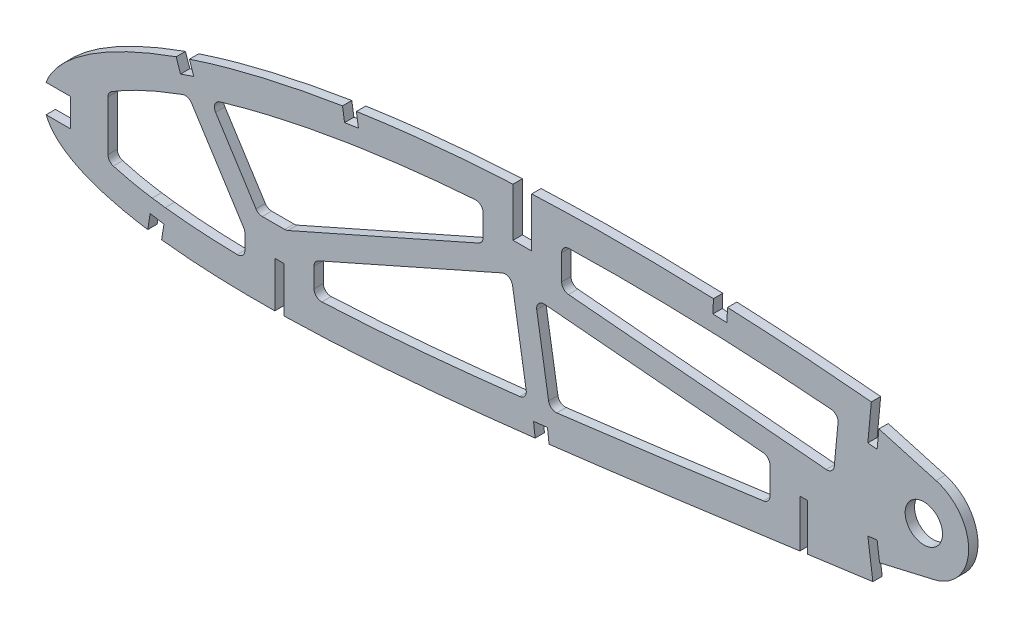
from build123d import *

# Parameters (mm, degrees)
BOSS_EXTRUDE1_DEPTH = 3.175
CUT_EXTRUDE1_DEPTH  = 7.62
SKETCH3_R           = 6.35
CUT_EXTRUDE2_DEPTH  = 7.62
CUT_EXTRUDE3_DEPTH  = 460.680430564
CUT_EXTRUDE4_DEPTH  = 320.461002544
FILLET1_R           = 2.54


with BuildPart() as part:
    # Sketch1 → Boss-Extrude1 (new body)
    with BuildSketch(Plane.XY):
        with BuildLine():
            Line((452.103130844, 0.704841059), (456.093968789, -1.676407199))
            Line((456.093968789, -1.676407199), (451.539257956, -0.704841059))
            add(Edge.make_bspline(
                [(0, 0), (0.116098484, -0.548062271), (0.348829019, -1.646705608), (0.981127511, -3.228296827), (1.817312083, -4.748664111), (2.874932324, -6.203769023), (4.146956076, -7.593213852), (5.630573928, -8.918443806), (7.324330898, -10.17874635), (9.226010202, -11.373547856), (11.332849305, -12.504116729), (13.642480166, -13.569749989), (16.152796843, -14.570114683), (18.861064307, -15.503873502), (21.763971588, -16.372448625), (24.858758771, -17.173723352), (28.141906776, -17.908817596), (31.610257831, -18.575854993), (35.260032504, -19.175513209), (39.087439203, -19.707456616), (43.088549366, -20.172017908), (47.259437594, -20.568222339), (51.595978462, -20.896922095), (56.093849686, -21.158335191), (60.748685259, -21.353290574), (65.556026339, -21.481047186), (70.511164689, -21.543596642), (75.60962225, -21.541878079), (80.846411515, -21.475431763), (86.217059019, -21.347928406), (91.716411041, -21.158560481), (97.339502767, -20.909619435), (103.081262098, -20.60361064), (108.936539298, -20.241571378), (114.900181528, -19.825106256), (120.967010704, -19.35755507), (127.131515672, -18.84008407), (133.388320155, -18.27570942), (139.73188498, -17.667256592), (146.156729407, -17.016651105), (152.657182369, -16.326953548), (159.227454029, -15.600398833), (165.861955098, -14.840863119), (172.554624992, -14.049720613), (179.299804335, -13.231488425), (186.0911476, -12.387729793), (192.922975871, -11.521694689), (199.789144556, -10.637460813), (206.683225759, -9.734927313), (213.599421065, -8.820524357), (220.53106073, -7.893498895), (227.472111233, -6.958618548), (234.416147314, -6.018789286), (241.356405409, -5.07430035), (248.28678484, -4.129065861), (255.200856388, -3.185680808), (262.091847615, -2.244231265), (268.953524037, -1.309396646), (275.778976202, -0.38106275), (282.561910312, 0.538888344), (289.295826346, 1.447710664), (295.974371147, 2.344257157), (302.590655451, 3.227960607), (309.138022785, 4.099152889), (315.511866205, 4.931391047), (321.69553077, 5.768992271), (327.709854245, 6.4556395), (333.649291775, 7.04171769), (339.520012945, 7.522220911), (345.31496828, 7.904062197), (351.027518107, 8.189969928), (356.650854245, 8.383935735), (362.17787359, 8.491713952), (367.601672755, 8.516039607), (372.914848341, 8.464670411), (378.110490176, 8.34174704), (383.181346836, 8.152787103), (388.120344083, 7.904165623), (392.920466429, 7.60266025), (397.574507523, 7.252718477), (402.075982121, 6.8625098), (406.417945063, 6.437746476), (410.593729281, 5.983281443), (414.597241701, 5.508637621), (418.422074216, 5.016940024), (422.062473684, 4.516268978), (425.512580015, 4.011698392), (428.766929364, 3.509669922), (431.820408455, 3.014973074), (434.668085107, 2.534173613), (437.305498365, 2.071763811), (439.728071725, 1.632259415), (441.932444373, 1.221205742), (443.914262697, 0.840644737), (445.670876088, 0.49684807), (447.199018295, 0.19133282), (448.496449148, -0.071596745), (449.560902928, -0.290902855), (450.390762879, -0.462985534), (450.984389878, -0.5881196), (451.34114184, -0.662580877), (451.499651332, -0.696392563), (451.539257956, -0.704841059)],
                knots=[0, 0, 0, 0, 0.003638255, 0.007293231, 0.011028136, 0.014901081, 0.018963272, 0.023258475, 0.027820626, 0.032679082, 0.03785316, 0.043361875, 0.049214679, 0.055422346, 0.061988786, 0.068918036, 0.076211157, 0.083868392, 0.091887411, 0.100265912, 0.108999867, 0.118084529, 0.127514843, 0.13728527, 0.147387917, 0.157816481, 0.168563473, 0.179619128, 0.190977373, 0.202626974, 0.214560478, 0.226767249, 0.239236417, 0.251959004, 0.264923894, 0.278119703, 0.291536035, 0.30516028, 0.318980685, 0.332985499, 0.34716279, 0.361498603, 0.375980747, 0.390597192, 0.405332593, 0.420174823, 0.435109533, 0.450124276, 0.465203068, 0.480333154, 0.495500583, 0.510689775, 0.525887334, 0.541078314, 0.556247233, 0.571381785, 0.58646604, 0.601484515, 0.616424329, 0.631269423, 0.646006524, 0.660620684, 0.675098187, 0.689422858, 0.703581825, 0.716907563, 0.730009274, 0.742952128, 0.755725557, 0.768319951, 0.780724337, 0.792926528, 0.804916041, 0.816679084, 0.828203525, 0.8394749, 0.850481359, 0.861207697, 0.871639326, 0.881763414, 0.891563605, 0.901027365, 0.910138977, 0.918883977, 0.927249278, 0.935221104, 0.942784739, 0.949928188, 0.956638465, 0.962904203, 0.968712288, 0.974054485, 0.978918432, 0.983297219, 0.987180246, 0.990560674, 0.993433357, 0.995790626, 0.997629588, 0.998945816, 0.999736592, 1, 1, 1, 1], degree=3))
            add(Edge.make_bspline(
                [(452.103130844, 0.704841059), (452.068496813, 0.726236426), (451.930095213, 0.811734792), (451.618251437, 1.003015711), (451.098966561, 1.321603382), (450.372013154, 1.765285304), (449.437955605, 2.332883088), (448.296324058, 3.020422222), (446.947831268, 3.825669225), (445.392803438, 4.744815234), (443.631400049, 5.773556989), (441.66429165, 6.907726386), (439.491649667, 8.140902925), (437.114315549, 9.468047233), (434.533105048, 10.882848063), (431.748506266, 12.378914822), (428.761516485, 13.948638114), (425.573282246, 15.58526602), (422.184384898, 17.279761053), (418.59642206, 19.025070833), (414.810589229, 20.812493246), (410.828178709, 22.632492429), (406.65147817, 24.477648573), (402.281642423, 26.336490908), (397.721161703, 28.200965635), (392.971977542, 30.06046153), (388.036901986, 31.906510246), (382.917838926, 33.727152381), (377.618614974, 35.514431666), (372.141800823, 37.256737501), (366.491313143, 38.944607324), (360.670434952, 40.56709799), (354.684018662, 42.115888344), (348.535860801, 43.579699531), (342.231172339, 44.948733274), (335.774964791, 46.214747245), (329.172652762, 47.36510198), (322.442531978, 48.398900537), (315.692888447, 49.25884604), (308.957131835, 50.102255317), (302.231406377, 50.894561333), (295.423478513, 51.653303868), (288.539897863, 52.374211064), (281.587492313, 53.055028822), (274.573300246, 53.692818583), (267.504610588, 54.285710178), (260.388263375, 54.830343915), (253.231762389, 55.325880728), (246.04218283, 55.767964282), (238.827182474, 56.156262652), (231.594085468, 56.488067665), (224.350419046, 56.761093174), (217.103874943, 56.973690929), (209.861975326, 57.123824182), (202.632561324, 57.210549036), (195.423152651, 57.231495803), (188.241586793, 57.186289729), (181.095384018, 57.073378669), (173.992389816, 56.89121691), (166.940134698, 56.63946441), (159.9462446, 56.318230463), (153.018377106, 55.924824851), (146.164047723, 55.461754745), (139.39088931, 54.92707481), (132.706343647, 54.320642895), (126.117416199, 53.644986873), (119.631442696, 52.898268934), (113.255374135, 52.082613865), (106.996184656, 51.199620764), (100.86089724, 50.248808671), (94.856084142, 49.232924024), (88.98822628, 48.153006108), (83.263531815, 47.012221039), (77.688233433, 45.810866329), (72.268232878, 44.552545746), (67.009162956, 43.23945158), (61.916677035, 41.873987713), (56.99593741, 40.459430694), (52.251920045, 38.998989643), (47.690155321, 37.494269359), (43.314090924, 35.950975056), (39.129102409, 34.370202293), (35.138395613, 32.756820932), (31.346647327, 31.113033952), (27.756690145, 29.443852436), (24.372587071, 27.751176724), (21.196749975, 26.039749097), (18.232367129, 24.312193837), (15.482292083, 22.571719722), (12.9476807, 20.82274152), (10.632027491, 19.066357057), (8.536127933, 17.307004609), (6.661308341, 15.547363257), (5.010248609, 13.788645116), (3.582889331, 12.033947283), (2.381101114, 10.284659424), (1.405092396, 8.542436815), (0.657070826, 6.808544998), (0.13629461, 5.083959089), (-0.148774805, 3.371224525), (-0.21973029, 1.668968236), (-0.073133992, 0.555491501), (0, 0)],
                knots=[0, 0, 0, 0, 0.00025409, 0.001015373, 0.002283359, 0.004056577, 0.006330982, 0.009105274, 0.012374489, 0.016134023, 0.02037966, 0.025105976, 0.030306237, 0.035972206, 0.042099522, 0.048678064, 0.055701664, 0.063160184, 0.071045824, 0.079349826, 0.08806291, 0.097175756, 0.106678112, 0.116561573, 0.126814275, 0.137428301, 0.148393618, 0.15969976, 0.171338126, 0.183297699, 0.195569604, 0.208143556, 0.221011593, 0.234161831, 0.24758745, 0.261276822, 0.27522271, 0.289414144, 0.303771199, 0.317689227, 0.331784111, 0.346039677, 0.36044387, 0.37498272, 0.389640454, 0.404403316, 0.419256601, 0.434186749, 0.449177265, 0.464214782, 0.479284009, 0.49436974, 0.509457833, 0.524532346, 0.53957932, 0.554582984, 0.569529546, 0.584403417, 0.599190992, 0.613876838, 0.628447475, 0.642888675, 0.657186054, 0.671325546, 0.685294014, 0.699078147, 0.712665095, 0.726042645, 0.739197713, 0.752117586, 0.764792042, 0.777208152, 0.789355685, 0.80122396, 0.812803686, 0.824082909, 0.835054602, 0.845709571, 0.856037853, 0.866033834, 0.875688843, 0.884997719, 0.893953426, 0.902552897, 0.910789386, 0.918660734, 0.926166253, 0.933302626, 0.94007122, 0.94647478, 0.952517526, 0.958204819, 0.963546652, 0.9685566, 0.973249913, 0.977651041, 0.981787043, 0.985694226, 0.989415109, 0.993001157, 0.996508416, 1, 1, 1, 1], degree=3))
        make_face()
    extrude(amount=BOSS_EXTRUDE1_DEPTH)

    # Sketch2 → Cut-Extrude1 (cut)
    with BuildSketch(Plane(origin=(0, 0, 0), x_dir=(-1, 0, 0), z_dir=(0, 0, -1))):
        Polygon((-81.649081478, -6.010725061), (-78.474081478, -6.010725061), (-78.474081478, -20.922752068), (-78.474081478, -21.704811205), (-81.649081478, -22.486870342), (-81.649081478, -20.922752068), align=None)
        Polygon((-259.449081478, 13.22073836), (-259.449081478, -2.652607086), (-259.449081478, -5.069769756), (-256.909081478, -3.861188421), (-256.909081478, -2.652607086), (-256.909081478, 13.22073836), align=None)
        Polygon((-165.786581478, 56.593547672), (-165.786581478, 39.762876916), (-159.436581478, 39.762876916), (-159.436581478, 56.593547672), (-159.436581478, 57.557196897), (-165.786581478, 58.520846121), align=None)
    extrude(amount=-CUT_EXTRUDE1_DEPTH, mode=Mode.SUBTRACT)

    # Sketch3 → Cut-Extrude2 (cut)
    with BuildSketch(Plane(origin=(0, 0, 0), x_dir=(-1, 0, 0), z_dir=(0, 0, -1))):
        with Locations((-299.038447077, 26.255421435)):
            Circle(SKETCH3_R)
    extrude(amount=-CUT_EXTRUDE2_DEPTH, mode=Mode.SUBTRACT)

    # Sketch4 → Cut-Extrude3 (cut, through all)
    with BuildSketch(Plane.XY.offset(3.175)):
        with BuildLine():
            Line((9.076666365, 6.890948983), (0.724721742, 6.890948983))
            add(Edge.make_bspline(
                [(0.724721742, 6.890948983), (0.709496177, 6.850122056), (0.488246053, 6.249470262), (0.13629461, 5.083959089), (-0.148774805, 3.371224525), (-0.21973029, 1.668968236), (-0.073133992, 0.555491501), (0, 0)],
                knots=[0.985422425, 0.985422425, 0.985422425, 0.985422425, 0.985694226, 0.989415109, 0.993001157, 0.996508416, 1, 1, 1, 1], degree=3))
            add(Edge.make_bspline(
                [(0, 0), (0.116098484, -0.548062271), (0.305939132, -1.444236737), (0.619159788, -2.305351823), (0.755399229, -2.634051017)],
                knots=[0, 0, 0, 0, 0.003638255, 0.005949162, 0.005949162, 0.005949162, 0.005949162], degree=3))
            Line((0.755399229, -2.634051017), (9.076666365, -2.634051017))
            Line((9.076666365, -2.634051017), (9.076666365, 6.890948983))
        make_face()
        with BuildLine():
            Line((50.94528914, 33.718880333), (49.457984223, 38.072533111))
            add(Edge.make_bspline(
                [(49.457984223, 38.072533111), (48.852375707, 37.871291192), (47.347795701, 37.364546546), (45.848492359, 36.842318766), (44.953969582, 36.524088968)],
                knots=[0.862050759, 0.862050759, 0.862050759, 0.862050759, 0.866033834, 0.871959688, 0.871959688, 0.871959688, 0.871959688], degree=3))
            Line((44.953969582, 36.524088968), (46.438686443, 32.179166464))
            Line((46.438686443, 32.179166464), (50.94528914, 33.718880333))
        make_face()
        with BuildLine():
            add(Edge.make_bspline(
                [(35.310795336, -19.167418321), (36.550140988, -19.354805569), (38.11863538, -19.57232394), (39.689829469, -19.768564004), (40.017366507, -19.808559412)],
                knots=[0.092113445, 0.092113445, 0.092113445, 0.092113445, 0.100265912, 0.102412087, 0.102412087, 0.102412087, 0.102412087], degree=3))
            Line((40.017366507, -19.808559412), (40.056230108, -19.559199628))
            Line((40.056230108, -19.559199628), (40.810392071, -14.791064015))
            Line((40.810392071, -14.791064015), (36.113723666, -14.052515981))
            Line((36.113723666, -14.052515981), (35.373024236, -18.771000939))
            Line((35.373024236, -18.771000939), (35.310795336, -19.167418321))
        make_face()
        with BuildLine():
            Line((39.567645247, -22.694097363), (40.017366507, -19.808559412))
            add(Edge.make_bspline(
                [(35.310795336, -19.167418321), (36.550140988, -19.354805569), (38.11863538, -19.57232394), (39.689829469, -19.768564004), (40.017366507, -19.808559412)],
                knots=[0.092113445, 0.092113445, 0.092113445, 0.092113445, 0.100265912, 0.102412087, 0.102412087, 0.102412087, 0.102412087], degree=3))
            Line((35.310795336, -19.167418321), (34.872872851, -21.957120289))
            Line((34.872872851, -21.957120289), (39.567645247, -22.694097363))
        make_face()
        with BuildLine():
            Line((106.90066319, 46.481463728), (106.209861612, 51.068186439))
            add(Edge.make_bspline(
                [(106.209861612, 51.068186439), (104.629351245, 50.831477167), (103.050077247, 50.586505601), (101.472164136, 50.333054309)],
                knots=[0.740777655, 0.740777655, 0.740777655, 0.740777655, 0.750752382, 0.750752382, 0.750752382, 0.750752382], degree=3))
            Line((101.472164136, 50.333054309), (102.191303266, 45.7721599))
            Line((102.191303266, 45.7721599), (106.90066319, 46.481463728))
        make_face()
        with BuildLine():
            add(Edge.make_bspline(
                [(166.948991926, -14.709918965), (168.528216327, -14.525231657), (170.10720639, -14.338540702), (171.685988187, -14.15010551)],
                knots=[0.378399329, 0.378399329, 0.378399329, 0.378399329, 0.388741043, 0.388741043, 0.388741043, 0.388741043], degree=3))
            Line((171.685988187, -14.15010551), (171.13396989, -9.48059682))
            Line((171.13396989, -9.48059682), (166.404404763, -10.039712392))
            Line((166.404404763, -10.039712392), (166.948991926, -14.709918965))
        make_face()
        with BuildLine():
            Line((232.119167537, 51.839052458), (232.321761642, 56.447492051))
            add(Edge.make_bspline(
                [(232.321761642, 56.447492051), (232.079950316, 56.457793824), (230.485264408, 56.525079676), (228.890398482, 56.588062732), (227.537258876, 56.638361271)],
                knots=[0.477773375, 0.477773375, 0.477773375, 0.477773375, 0.479284009, 0.48773546, 0.48773546, 0.48773546, 0.48773546], degree=3))
            Line((227.537258876, 56.638361271), (227.36106217, 52.037340067))
            Line((227.36106217, 52.037340067), (232.119167537, 51.839052458))
        make_face()
        with BuildLine():
            Line((280.002959876, 40.404001741), (283.163447077, 40.103220767))
            Line((283.163447077, 40.103220767), (283.772153107, 46.420883565))
            Line((283.772153107, 46.420883565), (284.380859136, 52.738546364))
            Line((284.380859136, 52.738546364), (284.384742546, 52.778851653))
            add(Edge.make_bspline(
                [(284.384742546, 52.778851653), (283.458514825, 52.868893345), (282.400140093, 52.970319768), (281.341607713, 53.07007766), (281.209561744, 53.0824957)],
                knots=[0.369174414, 0.369174414, 0.369174414, 0.369174414, 0.37498272, 0.375810522, 0.375810522, 0.375810522, 0.375810522], degree=3))
            Line((281.209561744, 53.0824957), (281.206083771, 53.045950544))
            Line((281.206083771, 53.045950544), (280.002959876, 40.404001741))
        make_face()
        with BuildLine():
            add(Edge.make_bspline(
                [(284.384742546, 52.778851653), (283.458514825, 52.868893345), (282.400140093, 52.970319768), (281.341607713, 53.07007766), (281.209561744, 53.0824957)],
                knots=[0.369174414, 0.369174414, 0.369174414, 0.369174414, 0.37498272, 0.375810522, 0.375810522, 0.375810522, 0.375810522], degree=3))
            Line((284.384742546, 52.778851653), (284.770271334, 56.780193452))
            Line((284.770271334, 56.780193452), (281.590270423, 57.082831529))
            Line((281.590270423, 57.082831529), (281.209561744, 53.0824957))
        make_face()
        with BuildLine():
            Line((284.380859136, 52.738546364), (283.772153107, 46.420883565))
            Line((283.772153107, 46.420883565), (303.192982236, 40.918212356))
            ThreePointArc((303.192982236, 40.918212356), (311.195188331, 35.446245233), (314.278447077, 26.255421435))
            ThreePointArc((314.278447077, 26.255421435), (310.969793045, 16.773829618), (302.480470254, 11.409207222))
            Line((302.480470254, 11.409207222), (284.012930322, 7.127597139))
            Line((284.012930322, 7.127597139), (284.860476862, 0.848860649))
            add(Edge.make_bspline(
                [(284.860476862, 0.848860649), (286.34516108, 1.049390117), (290.056592049, 1.549837975), (295.974371147, 2.344257157), (302.590655451, 3.227960607), (309.138022785, 4.099152889), (315.511866205, 4.931391047), (321.69553077, 5.768992271), (327.709854245, 6.4556395), (333.649291775, 7.04171769), (339.520012945, 7.522220911), (345.31496828, 7.904062197), (351.027518107, 8.189969928), (356.650854245, 8.383935735), (362.17787359, 8.491713952), (367.601672755, 8.516039607), (372.914848341, 8.464670411), (378.110490176, 8.34174704), (383.181346836, 8.152787103), (388.120344083, 7.904165623), (392.920466429, 7.60266025), (397.574507523, 7.252718477), (402.075982121, 6.8625098), (406.417945063, 6.437746476), (410.593729281, 5.983281443), (414.597241701, 5.508637621), (418.422074216, 5.016940024), (422.062473684, 4.516268978), (425.512580015, 4.011698392), (428.766929364, 3.509669922), (431.820408455, 3.014973074), (434.668085107, 2.534173613), (437.305498365, 2.071763811), (439.728071725, 1.632259415), (441.932444373, 1.221205742), (443.914262697, 0.840644737), (445.670876088, 0.49684807), (447.199018295, 0.19133282), (448.496449148, -0.071596745), (449.560902928, -0.290902855), (450.390762879, -0.462985534), (450.984389878, -0.5881196), (451.34114184, -0.662580877), (451.499651332, -0.696392563), (451.539257956, -0.704841059)],
                knots=[0.63626204, 0.63626204, 0.63626204, 0.63626204, 0.646006524, 0.660620684, 0.675098187, 0.689422858, 0.703581825, 0.716907563, 0.730009274, 0.742952128, 0.755725557, 0.768319951, 0.780724337, 0.792926528, 0.804916041, 0.816679084, 0.828203525, 0.8394749, 0.850481359, 0.861207697, 0.871639326, 0.881763414, 0.891563605, 0.901027365, 0.910138977, 0.918883977, 0.927249278, 0.935221104, 0.942784739, 0.949928188, 0.956638465, 0.962904203, 0.968712288, 0.974054485, 0.978918432, 0.983297219, 0.987180246, 0.990560674, 0.993433357, 0.995790626, 0.997629588, 0.998945816, 0.999736592, 1, 1, 1, 1], degree=3))
            Line((451.539257956, -0.704841059), (456.093968789, -1.676407199))
            Line((456.093968789, -1.676407199), (452.103130844, 0.704841059))
            add(Edge.make_bspline(
                [(452.103130844, 0.704841059), (452.068496813, 0.726236426), (451.930095213, 0.811734792), (451.618251437, 1.003015711), (451.098966561, 1.321603382), (450.372013154, 1.765285304), (449.437955605, 2.332883088), (448.296324058, 3.020422222), (446.947831268, 3.825669225), (445.392803438, 4.744815234), (443.631400049, 5.773556989), (441.66429165, 6.907726386), (439.491649667, 8.140902925), (437.114315549, 9.468047233), (434.533105048, 10.882848063), (431.748506266, 12.378914822), (428.761516485, 13.948638114), (425.573282246, 15.58526602), (422.184384898, 17.279761053), (418.59642206, 19.025070833), (414.810589229, 20.812493246), (410.828178709, 22.632492429), (406.65147817, 24.477648573), (402.281642423, 26.336490908), (397.721161703, 28.200965635), (392.971977542, 30.06046153), (388.036901986, 31.906510246), (382.917838926, 33.727152381), (377.618614974, 35.514431666), (372.141800823, 37.256737501), (366.491313143, 38.944607324), (360.670434952, 40.56709799), (354.684018662, 42.115888344), (348.535860801, 43.579699531), (342.231172339, 44.948733274), (335.774964791, 46.214747245), (329.172652762, 47.36510198), (322.442531978, 48.398900537), (315.692888447, 49.25884604), (308.957131835, 50.102255317), (302.231406377, 50.894561333), (295.423478513, 51.653303868), (289.603246246, 52.262848164), (286.052736483, 52.616099696), (284.798474131, 52.738546364)],
                knots=[0, 0, 0, 0, 0.00025409, 0.001015373, 0.002283359, 0.004056577, 0.006330982, 0.009105274, 0.012374489, 0.016134023, 0.02037966, 0.025105976, 0.030306237, 0.035972206, 0.042099522, 0.048678064, 0.055701664, 0.063160184, 0.071045824, 0.079349826, 0.08806291, 0.097175756, 0.106678112, 0.116561573, 0.126814275, 0.137428301, 0.148393618, 0.15969976, 0.171338126, 0.183297699, 0.195569604, 0.208143556, 0.221011593, 0.234161831, 0.24758745, 0.261276822, 0.27522271, 0.289414144, 0.303771199, 0.317689227, 0.331784111, 0.346039677, 0.36044387, 0.368309569, 0.368309569, 0.368309569, 0.368309569], degree=3))
            Line((284.798474131, 52.738546364), (284.380859136, 52.738546364))
        make_face()
        with BuildLine():
            Line((284.860476862, 0.848860649), (284.012930322, 7.127597139))
            Line((284.012930322, 7.127597139), (283.163447077, 13.420680993))
            Line((283.163447077, 13.420680993), (280.017033521, 12.995599475))
            Line((280.017033521, 12.995599475), (281.715516034, 0.4235911))
            add(Edge.make_bspline(
                [(281.715516034, 0.4235911), (282.003163555, 0.462531675), (283.051468053, 0.604404862), (284.099794103, 0.746118727), (284.860476862, 0.848860649)],
                knots=[0.629381417, 0.629381417, 0.629381417, 0.629381417, 0.631269423, 0.63626204, 0.63626204, 0.63626204, 0.63626204], degree=3))
        make_face()
        with BuildLine():
            Line((284.862413567, 0.834513285), (284.860476862, 0.848860649))
            add(Edge.make_bspline(
                [(281.715516034, 0.4235911), (282.003163555, 0.462531675), (283.051468053, 0.604404862), (284.099794103, 0.746118727), (284.860476862, 0.848860649)],
                knots=[0.629381417, 0.629381417, 0.629381417, 0.629381417, 0.631269423, 0.63626204, 0.63626204, 0.63626204, 0.63626204], degree=3))
            Line((281.715516034, 0.4235911), (281.717359592, 0.40994525))
            Line((281.717359592, 0.40994525), (282.089214064, -2.342486696))
            Line((282.089214064, -2.342486696), (285.235627617, -1.917405179))
            Line((285.235627617, -1.917405179), (284.862413567, 0.834513285))
        make_face()
        with BuildLine():
            Line((466.088227074, 52.738546364), (284.798474131, 52.738546364))
            add(Edge.make_bspline(
                [(452.103130844, 0.704841059), (452.068496813, 0.726236426), (451.930095213, 0.811734792), (451.618251437, 1.003015711), (451.098966561, 1.321603382), (450.372013154, 1.765285304), (449.437955605, 2.332883088), (448.296324058, 3.020422222), (446.947831268, 3.825669225), (445.392803438, 4.744815234), (443.631400049, 5.773556989), (441.66429165, 6.907726386), (439.491649667, 8.140902925), (437.114315549, 9.468047233), (434.533105048, 10.882848063), (431.748506266, 12.378914822), (428.761516485, 13.948638114), (425.573282246, 15.58526602), (422.184384898, 17.279761053), (418.59642206, 19.025070833), (414.810589229, 20.812493246), (410.828178709, 22.632492429), (406.65147817, 24.477648573), (402.281642423, 26.336490908), (397.721161703, 28.200965635), (392.971977542, 30.06046153), (388.036901986, 31.906510246), (382.917838926, 33.727152381), (377.618614974, 35.514431666), (372.141800823, 37.256737501), (366.491313143, 38.944607324), (360.670434952, 40.56709799), (354.684018662, 42.115888344), (348.535860801, 43.579699531), (342.231172339, 44.948733274), (335.774964791, 46.214747245), (329.172652762, 47.36510198), (322.442531978, 48.398900537), (315.692888447, 49.25884604), (308.957131835, 50.102255317), (302.231406377, 50.894561333), (295.423478513, 51.653303868), (289.603246246, 52.262848164), (286.052736483, 52.616099696), (284.798474131, 52.738546364)],
                knots=[0, 0, 0, 0, 0.00025409, 0.001015373, 0.002283359, 0.004056577, 0.006330982, 0.009105274, 0.012374489, 0.016134023, 0.02037966, 0.025105976, 0.030306237, 0.035972206, 0.042099522, 0.048678064, 0.055701664, 0.063160184, 0.071045824, 0.079349826, 0.08806291, 0.097175756, 0.106678112, 0.116561573, 0.126814275, 0.137428301, 0.148393618, 0.15969976, 0.171338126, 0.183297699, 0.195569604, 0.208143556, 0.221011593, 0.234161831, 0.24758745, 0.261276822, 0.27522271, 0.289414144, 0.303771199, 0.317689227, 0.331784111, 0.346039677, 0.36044387, 0.368309569, 0.368309569, 0.368309569, 0.368309569], degree=3))
            Line((452.103130844, 0.704841059), (456.093968789, -1.676407199))
            Line((456.093968789, -1.676407199), (451.539257956, -0.704841059))
            add(Edge.make_bspline(
                [(284.860476862, 0.848860649), (286.34516108, 1.049390117), (290.056592049, 1.549837975), (295.974371147, 2.344257157), (302.590655451, 3.227960607), (309.138022785, 4.099152889), (315.511866205, 4.931391047), (321.69553077, 5.768992271), (327.709854245, 6.4556395), (333.649291775, 7.04171769), (339.520012945, 7.522220911), (345.31496828, 7.904062197), (351.027518107, 8.189969928), (356.650854245, 8.383935735), (362.17787359, 8.491713952), (367.601672755, 8.516039607), (372.914848341, 8.464670411), (378.110490176, 8.34174704), (383.181346836, 8.152787103), (388.120344083, 7.904165623), (392.920466429, 7.60266025), (397.574507523, 7.252718477), (402.075982121, 6.8625098), (406.417945063, 6.437746476), (410.593729281, 5.983281443), (414.597241701, 5.508637621), (418.422074216, 5.016940024), (422.062473684, 4.516268978), (425.512580015, 4.011698392), (428.766929364, 3.509669922), (431.820408455, 3.014973074), (434.668085107, 2.534173613), (437.305498365, 2.071763811), (439.728071725, 1.632259415), (441.932444373, 1.221205742), (443.914262697, 0.840644737), (445.670876088, 0.49684807), (447.199018295, 0.19133282), (448.496449148, -0.071596745), (449.560902928, -0.290902855), (450.390762879, -0.462985534), (450.984389878, -0.5881196), (451.34114184, -0.662580877), (451.499651332, -0.696392563), (451.539257956, -0.704841059)],
                knots=[0.63626204, 0.63626204, 0.63626204, 0.63626204, 0.646006524, 0.660620684, 0.675098187, 0.689422858, 0.703581825, 0.716907563, 0.730009274, 0.742952128, 0.755725557, 0.768319951, 0.780724337, 0.792926528, 0.804916041, 0.816679084, 0.828203525, 0.8394749, 0.850481359, 0.861207697, 0.871639326, 0.881763414, 0.891563605, 0.901027365, 0.910138977, 0.918883977, 0.927249278, 0.935221104, 0.942784739, 0.949928188, 0.956638465, 0.962904203, 0.968712288, 0.974054485, 0.978918432, 0.983297219, 0.987180246, 0.990560674, 0.993433357, 0.995790626, 0.997629588, 0.998945816, 0.999736592, 1, 1, 1, 1], degree=3))
            Line((284.860476862, 0.848860649), (284.862413567, 0.834513285))
            Line((284.862413567, 0.834513285), (466.088227074, -18.771000939))
            Line((466.088227074, -18.771000939), (466.088227074, 52.738546364))
        make_face()
    extrude(amount=-CUT_EXTRUDE3_DEPTH, mode=Mode.SUBTRACT)


with BuildPart() as cut_extrude3_kept_piece:
    # of the separate pieces the step leaves, the one the design keeps (cut_extrude3_pieces_kept)
    add(part.part.solids().sort_by_distance((232.321761642, 56.447492051, 0))[0])

    # Sketch5 → Cut-Extrude4 (cut, through all)
    with BuildSketch(Plane.XY.offset(3.175)):
        with BuildLine():
            add(Edge.make_bspline(
                [(21.776666365, -5.747352918), (22.113502893, -5.856985447), (22.793449551, -6.071677475), (24.78732074, -6.665210829), (27.919685234, -7.474335415), (32.264479935, -8.380888338), (35.311872265, -8.892103539), (36.829708633, -9.121598175)],
                knots=[0.055006333, 0.055006333, 0.055006333, 0.055006333, 0.057698966, 0.0603916, 0.070572375, 0.08134291, 0.092113445, 0.092113445, 0.092113445, 0.092113445], degree=3))
            Line((36.829708633, -9.121598175), (41.248852551, -9.723469322))
            add(Edge.make_bspline(
                [(41.248852551, -9.723469322), (42.758212792, -9.907776656), (45.773395172, -10.235170642), (51.885654424, -10.756253149), (59.392149246, -11.170006324), (65.403526556, -11.316703139), (68.314081478, -11.35226521)],
                knots=[0.102412087, 0.102412087, 0.102412087, 0.102412087, 0.112851931, 0.123291776, 0.144171465, 0.163633402, 0.163633402, 0.163633402, 0.163633402], degree=3))
            Line((68.314081478, -11.35226521), (68.314081478, -2.944168915))
            Line((68.314081478, -2.944168915), (49.112541076, 27.210720331))
            Line((49.112541076, 27.210720331), (48.359351671, 26.951786589))
            add(Edge.make_bspline(
                [(48.359351671, 26.951786589), (46.327051441, 26.228788239), (42.2726582, 24.713369905), (36.351229286, 22.250428238), (30.606696685, 19.565917716), (26.200246894, 17.215797083), (23.310840075, 15.495098515), (22.195633669, 14.792474835), (21.776666365, 14.522445647)],
                knots=[0.871959688, 0.871959688, 0.871959688, 0.871959688, 0.88614253, 0.900325372, 0.914508214, 0.928691057, 0.934469309, 0.93801502, 0.93801502, 0.93801502, 0.93801502], degree=3))
            Line((21.776666365, 14.522445647), (21.776666365, -5.747352918))
        make_face()
        with BuildLine():
            Line((56.567275011, 29.690387083), (72.830929398, 4.149274939))
            Line((72.830929398, 4.149274939), (82.401104828, 4.149274939))
            Line((82.401104828, 4.149274939), (149.276581478, 33.769873793))
            Line((149.276581478, 33.769873793), (149.276581478, 45.48497375))
            add(Edge.make_bspline(
                [(149.276581478, 45.48497375), (148.461117807, 45.428450057), (143.271542371, 45.058169004), (133.728966045, 44.251429069), (120.679613621, 42.834488458), (112.032064191, 41.666849619), (107.714716991, 41.020250816)],
                knots=[0.652108864, 0.652108864, 0.652108864, 0.652108864, 0.657294996, 0.685122549, 0.712950102, 0.740777655, 0.740777655, 0.740777655, 0.740777655], degree=3))
            Line((107.714716991, 41.020250816), (103.083454258, 40.301636456))
            add(Edge.make_bspline(
                [(103.083454258, 40.301636456), (98.788403433, 39.611746642), (90.207213091, 38.101001537), (77.48510802, 35.41602737), (66.252781995, 32.584660867), (59.34774855, 30.560487191), (56.567275011, 29.690387083)],
                knots=[0.750752382, 0.750752382, 0.750752382, 0.750752382, 0.778576976, 0.80640157, 0.834226165, 0.853162645, 0.853162645, 0.853162645, 0.853162645], degree=3))
        make_face()
        with BuildLine():
            Line((91.809081478, -0.017721939), (91.809081478, -10.977698198))
            add(Edge.make_bspline(
                [(91.809081478, -10.977698198), (91.850327892, -10.976039425), (95.390285769, -10.833286487), (105.951840754, -10.308151251), (123.515780864, -9.024316581), (144.151759364, -7.057111175), (157.773900506, -5.548051388), (164.337760971, -4.785503394)],
                knots=[0.215739949, 0.215739949, 0.215739949, 0.215739949, 0.216013438, 0.239211423, 0.285607391, 0.33200336, 0.375255674, 0.375255674, 0.375255674, 0.375255674], degree=3))
            Line((164.337760971, -4.785503394), (159.274675479, 26.383054007))
            ThreePointArc((159.274675479, 26.383054007), (157.977256776, 28.209213241), (155.738900793, 28.298181403))
            Line((155.738900793, 28.298181403), (91.809081478, -0.017721939))
        make_face()
        with BuildLine():
            Line((166.964589936, 26.567532329), (171.912257584, -3.890508193))
            add(Edge.make_bspline(
                [(171.912257584, -3.890508193), (172.031456971, -3.87620172), (178.634640162, -3.083129685), (192.315737028, -1.376017631), (212.977606558, 1.33427113), (231.319479133, 3.811506342), (242.581976085, 5.346312296), (246.749081478, 5.914913989)],
                knots=[0.391878822, 0.391878822, 0.391878822, 0.391878822, 0.392663266, 0.435331542, 0.48192204, 0.528512539, 0.555874043, 0.555874043, 0.555874043, 0.555874043], degree=3))
            Line((246.749081478, 5.914913989), (246.749081478, 19.556054472))
            Line((246.749081478, 19.556054472), (166.964589936, 26.567532329))
        make_face()
        with BuildLine():
            Line((175.946581478, 46.772554587), (175.946581478, 33.427560804))
            Line((175.946581478, 33.427560804), (268.36021076, 25.306231673))
            Line((268.36021076, 25.306231673), (270.12671756, 43.867984628))
            add(Edge.make_bspline(
                [(270.12671756, 43.867984628), (269.4767603, 43.922421238), (264.798006642, 44.309607109), (256.087087446, 44.967519612), (243.99082279, 45.725542729), (235.924202525, 46.124803088), (231.889312262, 46.296699593)],
                knots=[0.397188572, 0.397188572, 0.397188572, 0.397188572, 0.401301235, 0.426791948, 0.452282662, 0.477773375, 0.477773375, 0.477773375, 0.477773375], degree=3))
            Line((231.889312262, 46.296699593), (227.159854742, 46.485373232))
            add(Edge.make_bspline(
                [(227.159854742, 46.485373232), (222.077474167, 46.674294108), (211.906455154, 46.962763366), (196.660669325, 47.11161023), (184.673133046, 46.99252014), (177.773582226, 46.824267278), (175.946581478, 46.772554587)],
                knots=[0.48773546, 0.48773546, 0.48773546, 0.48773546, 0.519861968, 0.551988475, 0.584114983, 0.595689911, 0.595689911, 0.595689911, 0.595689911], degree=3))
        make_face()
    extrude(amount=-CUT_EXTRUDE4_DEPTH, mode=Mode.SUBTRACT)

    # Fillet1
    fillet1_edges = [cut_extrude3_kept_piece.edges().sort_by_distance(p)[0] for p in [
        (270.12671756, 43.867984628, 1.5875),
        (268.36021076, 25.306231673, 1.5875),
        (246.749081478, 5.914913989, 1.5875),
        (246.749081478, 19.556054472, 1.5875),
        (171.912257584, -3.890508193, 1.5875),
        (164.337760971, -4.785503394, 1.5875),
        (166.964589936, 26.567532329, 1.5875),
        (175.946581478, 33.427560804, 1.5875),
        (149.276581478, 45.48497375, 1.5875),
        (149.276581478, 33.769873793, 1.5875),
        (91.809081478, -10.977698198, 1.5875),
        (91.809081478, -0.017721939, 1.5875),
        (68.314081478, -2.944168915, 1.5875),
        (68.314081478, -11.35226521, 1.5875),
        (82.401104828, 4.149274939, 1.5875),
        (72.830929398, 4.149274939, 1.5875),
        (175.946581478, 46.772554587, 1.5875),
        (56.567275011, 29.690387083, 1.5875),
        (49.112541076, 27.210720331, 1.5875),
        (21.776666365, 14.522445647, 1.5875),
        (21.776666365, -5.747352918, 1.5875),
    ]]
    fillet(fillet1_edges, radius=FILLET1_R)


solid = cut_extrude3_kept_piece.part
